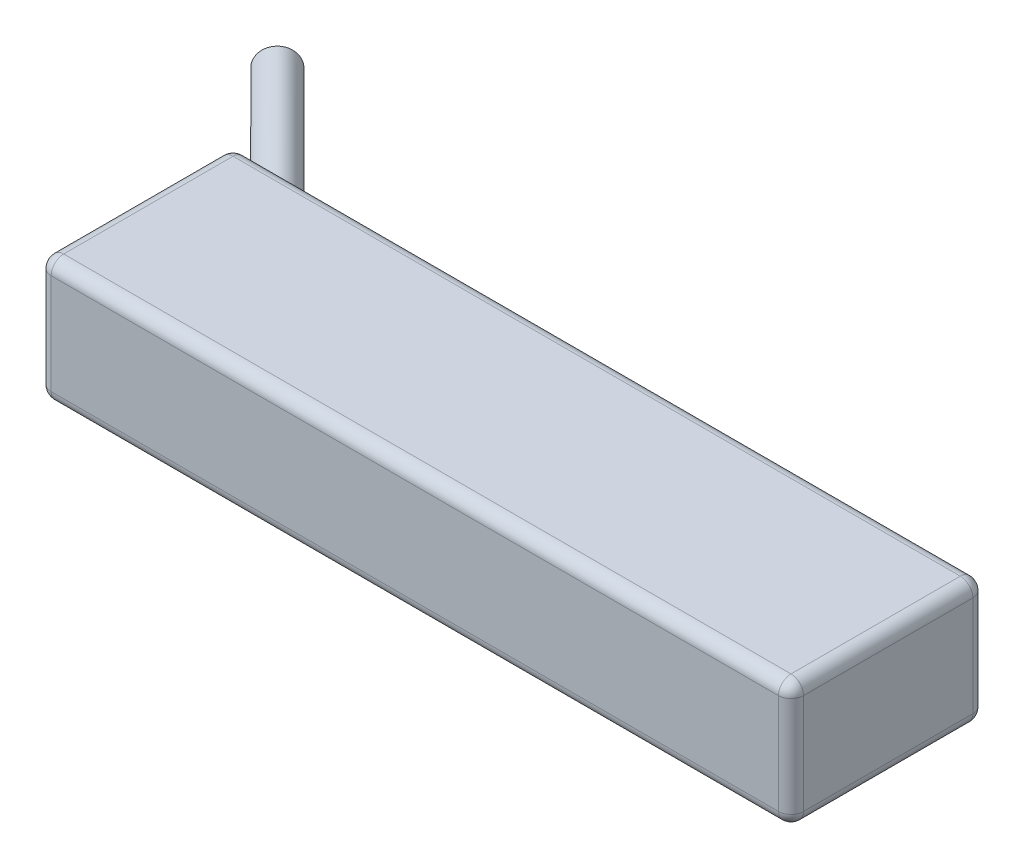
from build123d import *

# Parameters (mm, degrees)
SKETCH1_W           = 120
SKETCH1_H           = 31
BOSS_EXTRUDE1_DEPTH = 10
SKETCH4_R           = 3
BOSS_EXTRUDE2_DEPTH = 30
FILLET1_R           = 2


with BuildPart() as part:
    # Sketch1 → Boss-Extrude1 (new body, symmetric)
    with BuildSketch(Plane(origin=(0, 0, 0), x_dir=(1, 0, 0), z_dir=(0, 1, 0))):
        Rectangle(SKETCH1_W, SKETCH1_H)
    extrude(amount=BOSS_EXTRUDE1_DEPTH, both=True)

    # Sketch4 → Boss-Extrude2 (add)
    with BuildSketch(Plane(origin=(-32.75, 0, -32.75), x_dir=(0.707106781, 0, -0.707106781), z_dir=(0.707106781, 0, 0.707106781))):
        with Locations((-26.466251763, 4)):
            Circle(SKETCH4_R)
        with Locations((-26.466251763, -4)):
            Circle(SKETCH4_R)
    extrude(amount=-BOSS_EXTRUDE2_DEPTH)

    # Fillet1
    fillet1_edges = [part.edges().sort_by_distance(p)[0] for p in [
        (-60, 10, 0),
        (0, 10, 15.5),
        (60, 10, 0),
        (0, -10, 15.5),
        (-60, -10, 0),
        (0, -10, -15.5),
        (60, -10, 0),
        (60, 0, 15.5),
        (-60, 0, 15.5),
        (-60, 0, -15.5),
        (60, 0, -15.5),
        (0, 10, -15.5),
    ]]
    fillet(fillet1_edges, radius=FILLET1_R)


solid = part.part
